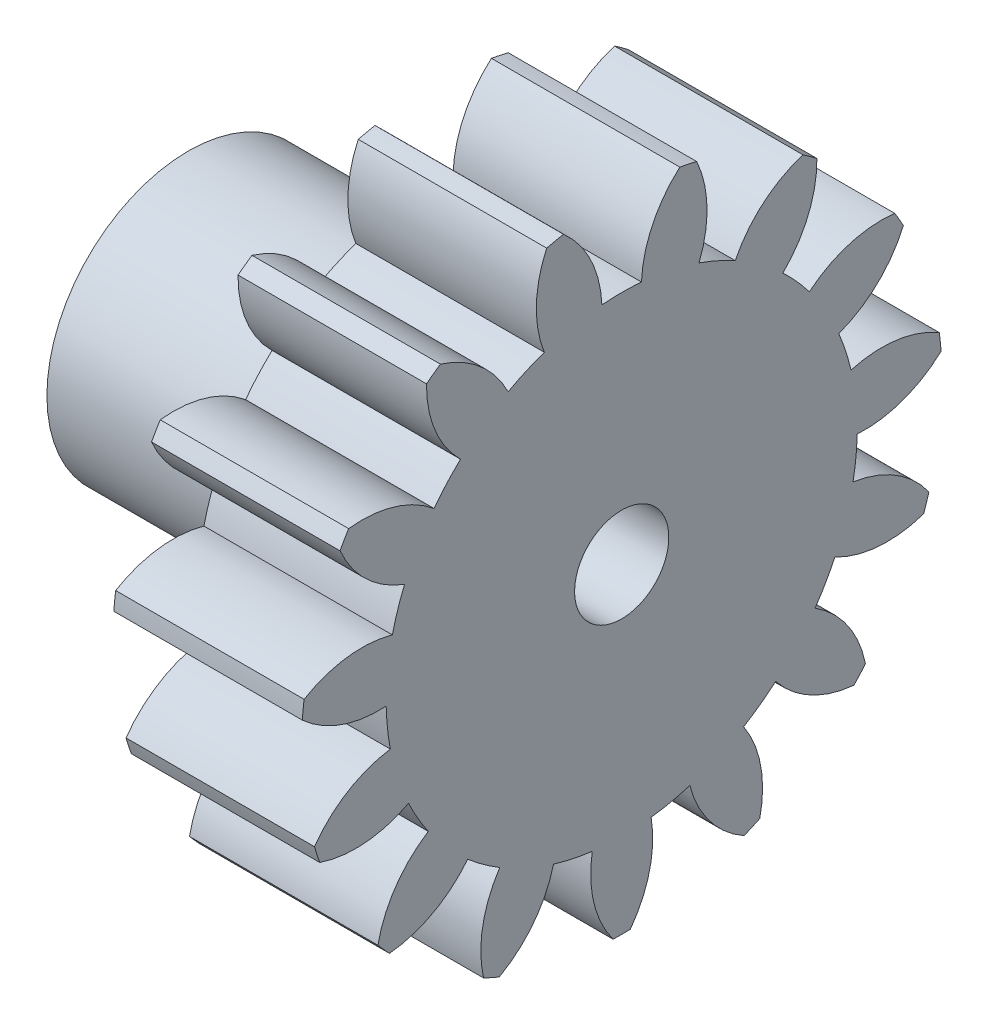
from build123d import *

# Parameters (mm, degrees)
BASPROSKE_W      = 10
BASPROSKE_H      = 17
TOOTHCUT_DEPTH   = 27.038433133
TEETHCUTS_COUNT  = 15
TEETHCUTS_ANGLE  = 336
HUBNEAONESKE_R   = 7.5
HUBNEARONE_DEPTH = 13.0000508
BORSKE_R         = 2.5
BORE_DEPTH       = 23.0000508


with BuildPart() as part:
    # BasProSke → Base-Revolve (revolve)
    with BuildSketch(Plane(origin=(0, 0, 0), x_dir=(1, 0, 0), z_dir=(0, 1, 0)), mode=Mode.PRIVATE) as base_revolve_sk:
        with Locations((5, 8.5)):
            Rectangle(BASPROSKE_W, BASPROSKE_H)
    revolve(base_revolve_sk.sketch.rotate(Axis((-10, 0, 0), (1, 0, 0)), 180), axis=Axis((-10, 0, 0), (1, 0, 0)))

    # TooCutSke → ToothCut (cut, through all)
    with BuildSketch(Plane(origin=(0, 0, 0), x_dir=(0, 0, -1), z_dir=(1, 0, 0))):
        with BuildLine():
            ThreePointArc((1.050056448, 12.454813626), (0, 12.499), (-1.050056448, 12.454813626))
            ThreePointArc((-1.050056448, 12.454813626), (-1.638118106, 14.809604533), (-3.110934279, 16.73876737))
            ThreePointArc((-3.110934279, 16.73876737), (0, 17.0254), (3.110934279, 16.73876737))
            ThreePointArc((3.110934279, 16.73876737), (1.638118106, 14.809604533), (1.050056448, 12.454813626))
        make_face()
    toothcut = extrude(amount=TOOTHCUT_DEPTH, mode=Mode.SUBTRACT)

    # TeethCuts: ToothCut ×15 about axis
    teethcuts_axis = Axis((-10, 0, 0), (1, 0, 0))
    for i in range(1, TEETHCUTS_COUNT):
        add(toothcut.rotate(teethcuts_axis, i * TEETHCUTS_ANGLE / (TEETHCUTS_COUNT - 1)), mode=Mode.SUBTRACT)

    # HubNeaOneSke → HubNearOne (add)
    with BuildSketch(Plane.ZY):
        with Locations(Location((0, 0, 0), (0, 0, 180))):
            Circle(HUBNEAONESKE_R)
    extrude(amount=HUBNEARONE_DEPTH)

    # BorSke → Bore (cut, symmetric)
    with BuildSketch(Plane(origin=(0, 0, 0), x_dir=(0, 0, -1), z_dir=(1, 0, 0))):
        with Locations(Location((0, 0, 0), (0, 0, 180))):
            Circle(BORSKE_R)
    extrude(amount=BORE_DEPTH, both=True, mode=Mode.SUBTRACT)


solid = part.part
